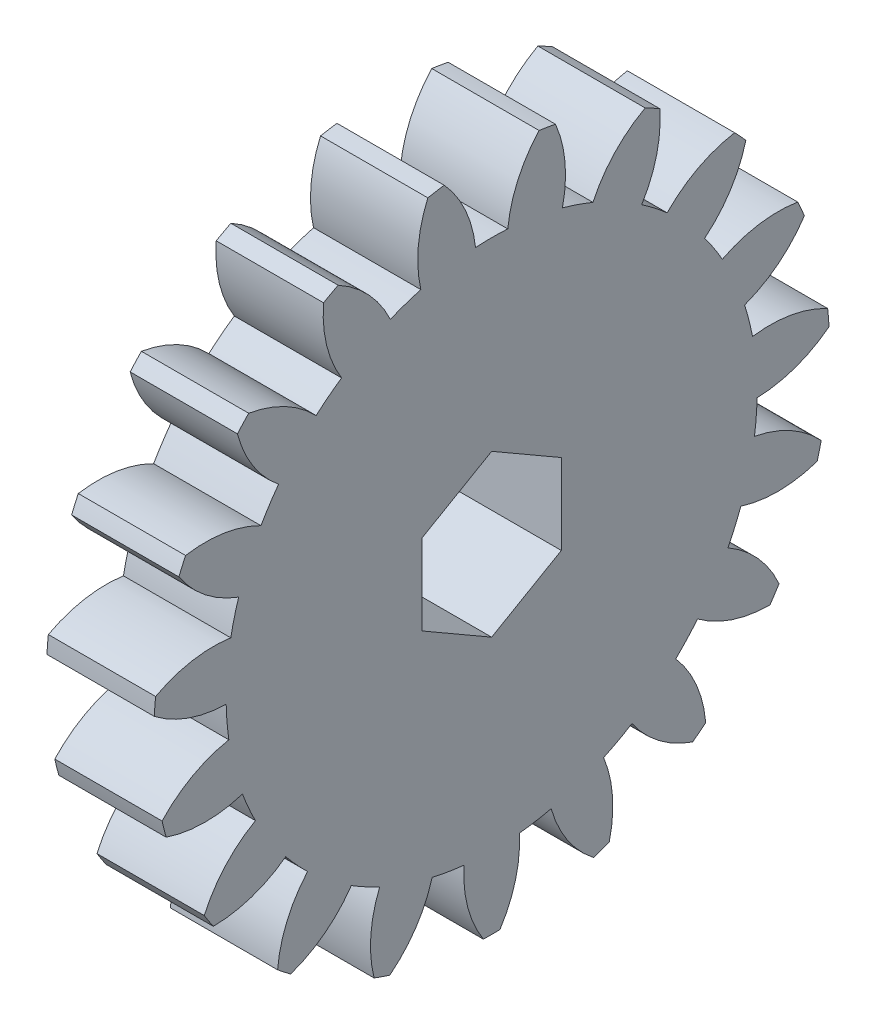
from build123d import *

# Parameters (mm, degrees)
BASPROSKE_W     = 5
BASPROSKE_H     = 15.75
TOOTHCUT_DEPTH  = 23.828162432
TEETHCUTS_COUNT = 19
TEETHCUTS_ANGLE = 341.052631579
BORE_DEPTH      = 50.0000508


with BuildPart() as part:
    # BasProSke → Base-Revolve (revolve)
    with BuildSketch(Plane(origin=(0, 0, 0), x_dir=(1, 0, 0), z_dir=(0, 1, 0)), mode=Mode.PRIVATE) as base_revolve_sk:
        with Locations((2.5, 7.875)):
            Rectangle(BASPROSKE_W, BASPROSKE_H)
    revolve(base_revolve_sk.sketch.rotate(Axis((-10, 0, 0), (1, 0, 0)), 180), axis=Axis((-10, 0, 0), (1, 0, 0)))

    # TooCutSke → ToothCut (cut, through all)
    with BuildSketch(Plane(origin=(0, 0, 0), x_dir=(0, 0, -1), z_dir=(1, 0, 0))):
        with BuildLine():
            ThreePointArc((0.751505376, 12.351158475), (0, 12.374), (-0.751505376, 12.351158475))
            ThreePointArc((-0.751505376, 12.351158475), (-1.227741339, 14.103349268), (-2.230855439, 15.616866817))
            ThreePointArc((-2.230855439, 15.616866817), (0, 15.7754), (2.230855439, 15.616866817))
            ThreePointArc((2.230855439, 15.616866817), (1.227741339, 14.103349268), (0.751505376, 12.351158475))
        make_face()
    toothcut = extrude(amount=TOOTHCUT_DEPTH, mode=Mode.SUBTRACT)

    # TeethCuts: ToothCut ×19 about axis
    teethcuts_axis = Axis((-10, 0, 0), (1, 0, 0))
    for i in range(1, TEETHCUTS_COUNT):
        add(toothcut.rotate(teethcuts_axis, i * TEETHCUTS_ANGLE / (TEETHCUTS_COUNT - 1)), mode=Mode.SUBTRACT)

    # BorSke → Bore (cut, symmetric)
    with BuildSketch(Plane(origin=(0, 0, 0), x_dir=(0, 0, -1), z_dir=(1, 0, 0))):
        Polygon((0, 3.75), (-3.247595264, 1.875), (-3.247595264, -1.875), (0, -3.75), (3.247595264, -1.875), (3.247595264, 1.875), align=None)
    extrude(amount=BORE_DEPTH, both=True, mode=Mode.SUBTRACT)


solid = part.part
